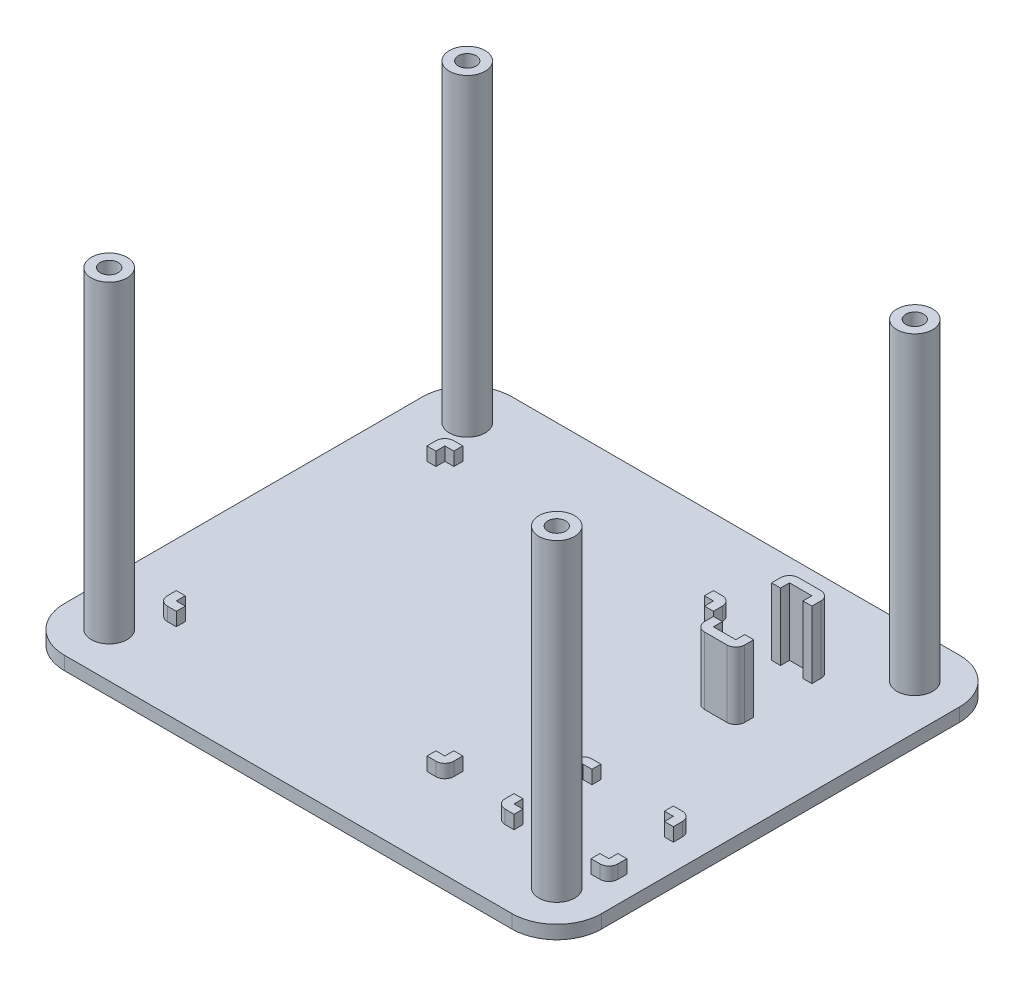
from build123d import *

# Parameters (mm, degrees)
ESQUISSE1_W             = 120
ESQUISSE1_H             = 100
BOSS_EXTRU_1_DEPTH      = 3
ESQUISSE2_W             = 2
ESQUISSE2_H             = 2
BOSS_EXTRU_2_DEPTH      = 3
ESQUISSE4_R             = 4
BOSS_EXTRU_4_DEPTH      = 70
ESQUISSE5_R             = 2
ENL_V_MAT_EXTRU_1_DEPTH = 70
CONG_1_R                = 10
BOSS_EXTRU_6_DEPTH      = 15
CONG_2_R                = 2


with BuildPart() as part:
    # Esquisse1 → Boss.-Extru.1 (new body)
    with BuildSketch(Plane(origin=(0, 0, 0), x_dir=(1, 0, 0), z_dir=(0, 1, 0))):
        with Locations((-60, 50)):
            Rectangle(ESQUISSE1_W, ESQUISSE1_H)
    extrude(amount=BOSS_EXTRU_1_DEPTH)

    # Esquisse2 → Boss.-Extru.2 (add)
    with BuildSketch(Plane(origin=(0, 3, 0), x_dir=(1, 0, 0), z_dir=(0, 1, 0))):
        Polygon((-105, 78), (-105, 80), (-103, 80), (-103, 82), (-107, 82), (-107, 78), align=None)
        Polygon((-105, 20), (-105, 22), (-107, 22), (-107, 18), (-103, 18), (-103, 20), align=None)
        Polygon((-43, 22), (-45, 22), (-45, 20), (-47, 20), (-47, 18), (-43, 18), align=None)
        Polygon((-47, 82), (-47, 80), (-45, 80), (-45, 78), (-43, 78), (-43, 82), align=None)
        with Locations((-6.8, 32.854127418)):
            Rectangle(ESQUISSE2_W, ESQUISSE2_H)
        with Locations((-6.8, 34.854127418)):
            Rectangle(ESQUISSE2_W, ESQUISSE2_H)
        with Locations((-8.8, 34.854127418)):
            Rectangle(ESQUISSE2_W, ESQUISSE2_H)
        with Locations((-27, 34.854127418)):
            Rectangle(ESQUISSE2_W, ESQUISSE2_H)
        with Locations((-29, 34.854127418)):
            Rectangle(ESQUISSE2_W, ESQUISSE2_H)
        with Locations((-29, 32.854127418)):
            Rectangle(ESQUISSE2_W, ESQUISSE2_H)
        with Locations((-29, 19.454127418)):
            Rectangle(ESQUISSE2_W, ESQUISSE2_H)
        with Locations((-29, 17.454127418)):
            Rectangle(ESQUISSE2_W, ESQUISSE2_H)
        with Locations((-27, 17.454127418)):
            Rectangle(ESQUISSE2_W, ESQUISSE2_H)
        with Locations((-5.8, 19.454127418)):
            Rectangle(ESQUISSE2_W, ESQUISSE2_H)
        with Locations((-5.8, 17.454127418)):
            Rectangle(ESQUISSE2_W, ESQUISSE2_H)
        with Locations((-7.8, 17.454127418)):
            Rectangle(ESQUISSE2_W, ESQUISSE2_H)
    extrude(amount=BOSS_EXTRU_2_DEPTH)

    # Esquisse4 → Boss.-Extru.4 (add)
    with BuildSketch(Plane(origin=(0, 3, 0), x_dir=(1, 0, 0), z_dir=(0, 1, 0))):
        with Locations((-10, 90)):
            Circle(ESQUISSE4_R)
        with Locations((-110, 90)):
            Circle(ESQUISSE4_R)
        with Locations((-110, 10)):
            Circle(ESQUISSE4_R)
        with Locations((-10, 10)):
            Circle(ESQUISSE4_R)
    extrude(amount=BOSS_EXTRU_4_DEPTH)

    # Esquisse5 → Enlèv. mat.-Extru.1 (cut)
    with BuildSketch(Plane(origin=(0, 73, 0), x_dir=(1, 0, 0), z_dir=(0, 1, 0))):
        with Locations((-110, 90)):
            Circle(ESQUISSE5_R)
        with Locations((-110, 10)):
            Circle(ESQUISSE5_R)
        with Locations((-10, 90)):
            Circle(ESQUISSE5_R)
        with Locations((-10, 10)):
            Circle(ESQUISSE5_R)
    extrude(amount=-ENL_V_MAT_EXTRU_1_DEPTH, mode=Mode.SUBTRACT)

    # Congé1
    cong_1_edges = [part.edges().sort_by_distance(p)[0] for p in [
        (0, 1.5, 0),
        (-120, 1.5, 0),
        (-120, 1.5, -100),
        (0, 1.5, -100),
    ]]
    fillet(cong_1_edges, radius=CONG_1_R)

    # Esquisse3 → Boss.-Extru.6 (add)
    with BuildSketch(Plane(origin=(0, 3, 0), x_dir=(1, 0, 0), z_dir=(0, 1, 0))):
        Polygon((-30, 78), (-28, 78), (-28, 80), (-23, 80), (-23, 78), (-21, 78), (-21, 82), (-28.2, 82), (-29.2, 82), (-30, 82), align=None)
        Polygon((-23, 63), (-28, 63), (-28, 65), (-30, 65), (-30, 61), (-26, 61), (-21, 61), (-21, 65), (-23, 65), align=None)
    extrude(amount=BOSS_EXTRU_6_DEPTH)

    # Congé2
    cong_2_edges = [part.edges().sort_by_distance(p)[0] for p in [
        (-30, 4.5, -16.454127418),
        (-4.8, 4.5, -16.454127418),
        (-107, 4.5, -82),
        (-21, 10.5, -82),
        (-30, 10.5, -82),
        (-30, 10.5, -61),
        (-21, 10.5, -61),
        (-107, 4.5, -18),
        (-43, 4.5, -18),
        (-43, 4.5, -82),
        (-5.8, 4.5, -35.854127418),
        (-30, 4.5, -35.854127418),
    ]]
    fillet(cong_2_edges, radius=CONG_2_R)


solid = part.part
